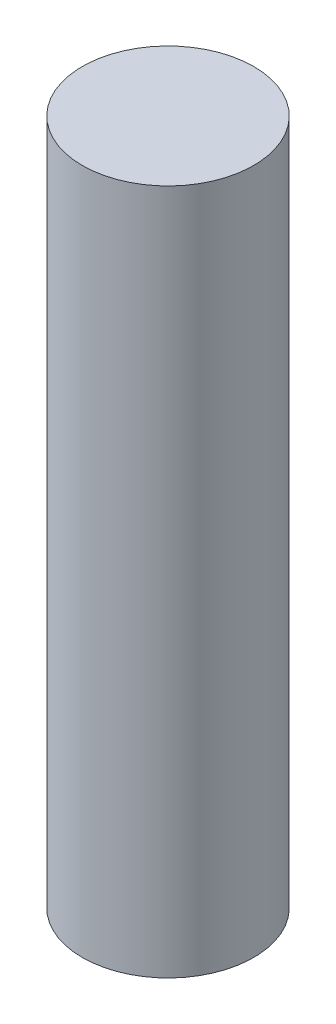
from build123d import *

# Parameters (mm, degrees)
SKETCH1_R           = 10
SKETCH1_R_2         = 7.5
BOSS_EXTRUDE1_DEPTH = 80
SKETCH2_R           = 7.5
BOSS_EXTRUDE2_DEPTH = 5


with BuildPart() as part:
    # Sketch1 → Boss-Extrude1 (new body)
    with BuildSketch(Plane(origin=(0, 0, 0), x_dir=(1, 0, 0), z_dir=(0, 1, 0))):
        Circle(SKETCH1_R)
        Circle(SKETCH1_R_2, mode=Mode.SUBTRACT)
    extrude(amount=BOSS_EXTRUDE1_DEPTH)

    # Sketch2 → Boss-Extrude2 (add)
    with BuildSketch(Plane(origin=(0, 80, 0), x_dir=(1, 0, 0), z_dir=(0, 1, 0))):
        Circle(SKETCH2_R)
    extrude(amount=-BOSS_EXTRUDE2_DEPTH)


solid = part.part
